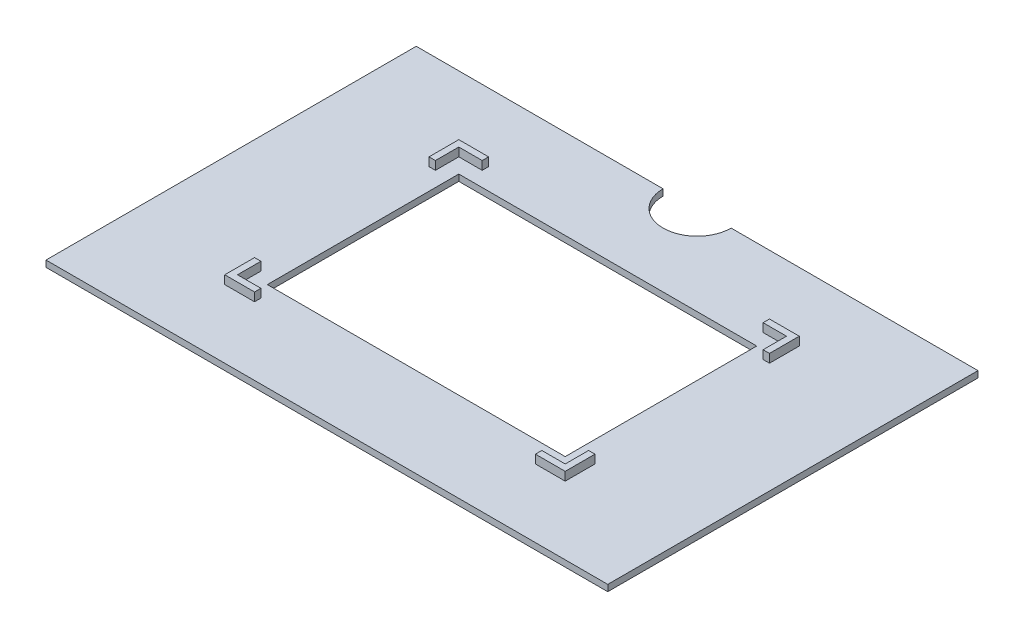
from build123d import *

# Parameters (mm, degrees)
SKETCH1_W           = 132
SKETCH1_H           = 87
BOSS_EXTRUDE1_DEPTH = 1.5
SKETCH2_W           = 80
SKETCH2_H           = 55
BOSS_EXTRUDE2_DEPTH = 2
SKETCH3_W           = 77
SKETCH3_H           = 52
CUT_EXTRUDE1_DEPTH  = 2
CUT_EXTRUDE2_REACH  = 3.5
SKETCH4_W           = 70
SKETCH4_H           = 45
SKETCH5_W           = 1.5
SKETCH5_H           = 41
SKETCH5_W_2         = 66
SKETCH5_H_2         = 1.5
CUT_EXTRUDE3_DEPTH  = 2
CUT_EXTRUDE4_DEPTH  = 1.5


with BuildPart() as part:
    # Sketch1 → Boss-Extrude1 (new body)
    with BuildSketch(Plane(origin=(0, 0, 0), x_dir=(1, 0, 0), z_dir=(0, 1, 0))):
        Rectangle(SKETCH1_W, SKETCH1_H)
    extrude(amount=BOSS_EXTRUDE1_DEPTH)

    # Sketch2 → Boss-Extrude2 (add)
    with BuildSketch(Plane(origin=(0, 1.5, 0), x_dir=(1, 0, 0), z_dir=(0, 1, 0))):
        Rectangle(SKETCH2_W, SKETCH2_H)
    extrude(amount=BOSS_EXTRUDE2_DEPTH)

    # Sketch3 → Cut-Extrude1 (cut)
    with BuildSketch(Plane(origin=(0, 3.5, 0), x_dir=(1, 0, 0), z_dir=(0, 1, 0))):
        Rectangle(SKETCH3_W, SKETCH3_H)
    extrude(amount=-CUT_EXTRUDE1_DEPTH, mode=Mode.SUBTRACT)

    # Sketch4 → Cut-Extrude2 (cut, up to next)
    with BuildSketch(Plane(origin=(0, 1.5, 0), x_dir=(1, 0, 0), z_dir=(0, 1, 0)), mode=Mode.PRIVATE) as cut_extrude2_sk1:
        Rectangle(SKETCH4_W, SKETCH4_H)
    cut_extrude2_tool1 = extrude(cut_extrude2_sk1.sketch, amount=-CUT_EXTRUDE2_REACH, mode=Mode.PRIVATE) & part.part
    add(cut_extrude2_tool1.solids().sort_by_distance((0, 1.5, 0))[0], mode=Mode.SUBTRACT)

    # Sketch5 → Cut-Extrude3 (cut)
    with BuildSketch(Plane(origin=(0, 3.5, 0), x_dir=(1, 0, 0), z_dir=(0, 1, 0))):
        with Locations((-39.25, 0)):
            Rectangle(SKETCH5_W, SKETCH5_H)
        with Locations((39.25, 0)):
            Rectangle(SKETCH5_W, SKETCH5_H)
        with Locations((0, 26.75)):
            Rectangle(SKETCH5_W_2, SKETCH5_H_2)
        with Locations((0, -26.75)):
            Rectangle(SKETCH5_W_2, SKETCH5_H_2)
    extrude(amount=-CUT_EXTRUDE3_DEPTH, mode=Mode.SUBTRACT)

    # Sketch6 → Cut-Extrude4 (cut)
    with BuildSketch(Plane(origin=(0, 1.5, 0), x_dir=(1, 0, 0), z_dir=(0, 1, 0))):
        with BuildLine():
            Line((-8, 43.5), (8, 43.5))
            ThreePointArc((8, 43.5), (0, 35.5), (-8, 43.5))
        make_face()
    extrude(amount=-CUT_EXTRUDE4_DEPTH, mode=Mode.SUBTRACT)


solid = part.part
